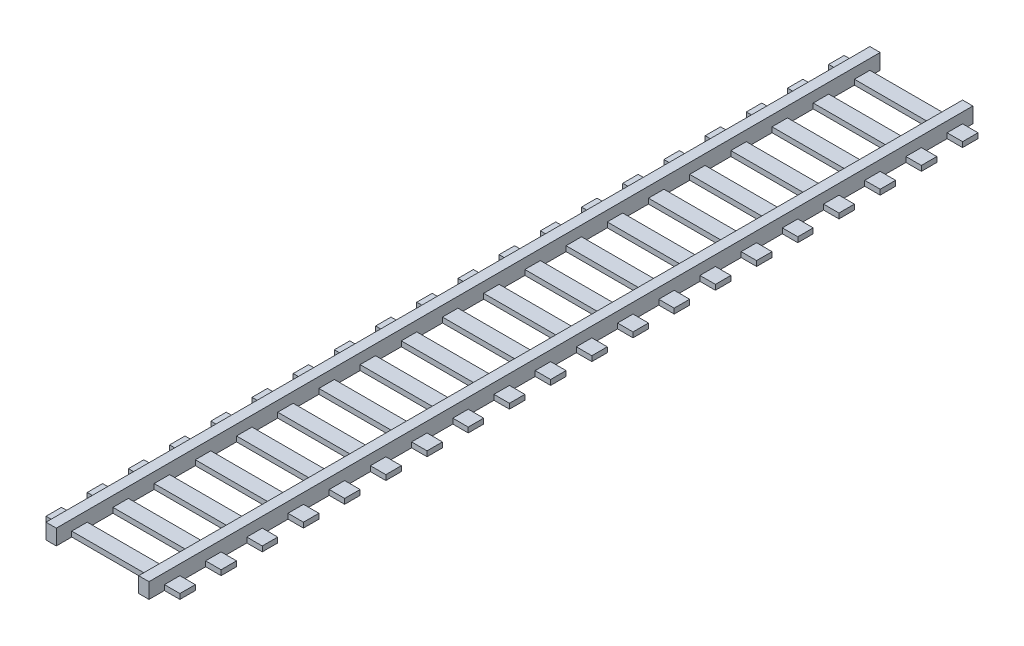
from build123d import *

# Parameters (mm, degrees)
SKETCH1_W             = 1
SKETCH1_H             = 160
BOSS_EXTRUDE1_DEPTH   = 3
BOSS_EXTRUDE1_2_DEPTH = 3
SKETCH2_W             = 1
SKETCH2_H             = 160
BOSS_EXTRUDE2_DEPTH   = 3
SKETCH3_W             = 26
SKETCH3_H             = 3
BOSS_EXTRUDE3_DEPTH   = 1


with BuildPart() as part:
    # Sketch1 → Boss-Extrude1 (new body)
    with BuildSketch(Plane(origin=(0, 0, 0), x_dir=(1, 0, 0), z_dir=(0, 1, 0))):
        with Locations((-43.187559699, -8.75)):
            Rectangle(SKETCH1_W, SKETCH1_H)
    extrude(amount=BOSS_EXTRUDE1_DEPTH)



with BuildPart() as body_2:
    # Sketch1 → Boss-Extrude1 2 (new body)
    with BuildSketch(Plane(origin=(0, 0, 0), x_dir=(1, 0, 0), z_dir=(0, 1, 0))):
        with Locations((-26.187559699, -8.75)):
            Rectangle(SKETCH1_W, SKETCH1_H)
    extrude(amount=BOSS_EXTRUDE1_2_DEPTH)


with BuildPart() as part_1:
    add(part.part)

    add(body_2.part)  # Boss-Extrude2 merges body 2
    # Sketch2 → Boss-Extrude2 (add)
    with BuildSketch(Plane.XZ):
        with Locations((-44.187559699, 8.75)):
            Rectangle(SKETCH2_W, SKETCH2_H)
        with Locations((-25.187559699, 8.75)):
            Rectangle(SKETCH2_W, SKETCH2_H)
    extrude(amount=-BOSS_EXTRUDE2_DEPTH)

    # Sketch3 → Boss-Extrude3 (add)
    with BuildSketch(Plane.XZ):
        with Locations((-34.687559699, 84.25)):
            Rectangle(SKETCH3_W, SKETCH3_H)
        with Locations((-34.687559699, 76.25)):
            Rectangle(SKETCH3_W, SKETCH3_H)
        with Locations((-34.687559699, 68.25)):
            Rectangle(SKETCH3_W, SKETCH3_H)
        with Locations((-34.687559699, 60.25)):
            Rectangle(SKETCH3_W, SKETCH3_H)
        with Locations((-34.687559699, 52.25)):
            Rectangle(SKETCH3_W, SKETCH3_H)
        with Locations((-34.687559699, 44.25)):
            Rectangle(SKETCH3_W, SKETCH3_H)
        with Locations((-34.687559699, 36.25)):
            Rectangle(SKETCH3_W, SKETCH3_H)
        with Locations((-34.687559699, 28.25)):
            Rectangle(SKETCH3_W, SKETCH3_H)
        with Locations((-34.687559699, 20.25)):
            Rectangle(SKETCH3_W, SKETCH3_H)
        with Locations((-34.687559699, 12.25)):
            Rectangle(SKETCH3_W, SKETCH3_H)
        with Locations((-34.687559699, 4.25)):
            Rectangle(SKETCH3_W, SKETCH3_H)
        with Locations((-34.687559699, -3.75)):
            Rectangle(SKETCH3_W, SKETCH3_H)
        with Locations((-34.687559699, -11.75)):
            Rectangle(SKETCH3_W, SKETCH3_H)
        with Locations((-34.687559699, -19.75)):
            Rectangle(SKETCH3_W, SKETCH3_H)
        with Locations((-34.687559699, -27.75)):
            Rectangle(SKETCH3_W, SKETCH3_H)
        with Locations((-34.687559699, -35.75)):
            Rectangle(SKETCH3_W, SKETCH3_H)
        with Locations((-34.687559699, -43.75)):
            Rectangle(SKETCH3_W, SKETCH3_H)
        with Locations((-34.687559699, -51.75)):
            Rectangle(SKETCH3_W, SKETCH3_H)
        with Locations((-34.687559699, -59.75)):
            Rectangle(SKETCH3_W, SKETCH3_H)
        with Locations((-34.687559699, -67.75)):
            Rectangle(SKETCH3_W, SKETCH3_H)
    extrude(amount=-BOSS_EXTRUDE3_DEPTH)


solid = part_1.part
